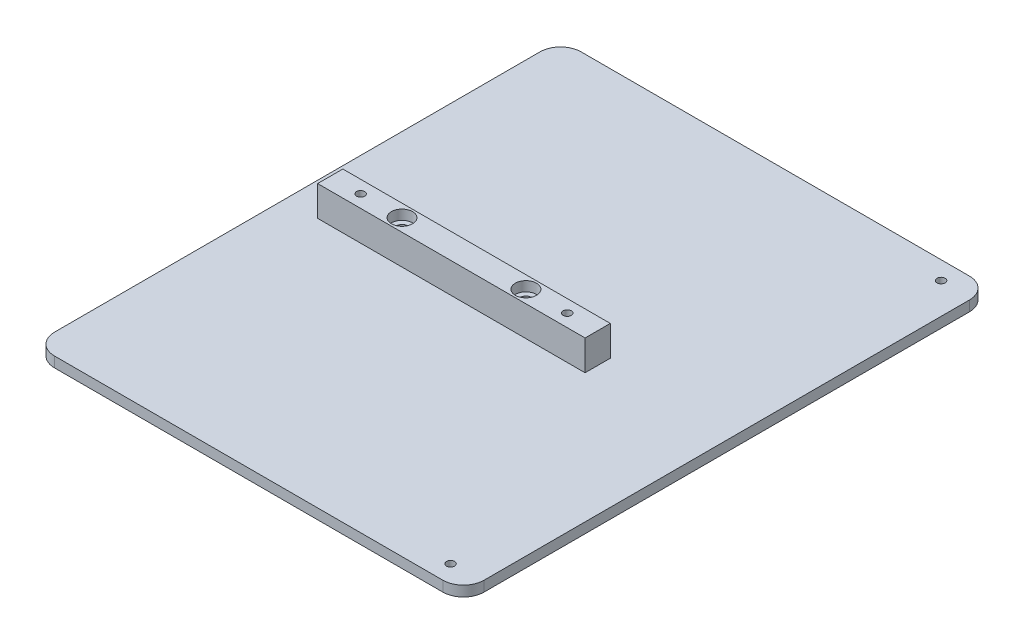
from build123d import *

# Parameters (mm, degrees)
SKETCH1_W                      = 132.08
SKETCH1_H                      = 161.925
BOSS_EXTRUDE1_DEPTH            = 3.175
FILLET1_R                      = 6.35
TAP_DRILL_FOR_M3X0_5_TAP1_D    = 2.5
SKETCH5_W                      = 82.226471496
SKETCH5_H                      = 7.747
BOSS_EXTRUDE2_DEPTH            = 9.271
TAP_DRILL_FOR_M3X0_5_TAP2_D    = 2.5
CBORE_FOR_M3_SHCS1_D           = 3.4
CBORE_FOR_M3_SHCS1_CBORE_D     = 6.5
CBORE_FOR_M3_SHCS1_CBORE_DEPTH = 3


with BuildPart() as part:
    # Sketch1 → Boss-Extrude1 (new body)
    with BuildSketch(Plane(origin=(0, 0, 0), x_dir=(1, 0, 0), z_dir=(0, 1, 0))):
        Rectangle(SKETCH1_W, SKETCH1_H)
    extrude(amount=BOSS_EXTRUDE1_DEPTH)

    # Fillet1
    fillet1_edges = [part.edges().sort_by_distance(p)[0] for p in [
        (-66.04, 1.5875, -80.9625),
        (66.04, 1.5875, -80.9625),
        (66.04, 1.5875, 80.9625),
        (-66.04, 1.5875, 80.9625),
    ]]
    fillet(fillet1_edges, radius=FILLET1_R)

    # Tap Drill for M3x0.5 Tap1 (through all)
    with Locations(Plane(origin=(0, 3.175, 0), x_dir=(1, 0, 0), z_dir=(0, 1, 0))):
        with Locations((56.515, -75.40625), (56.515, 75.40625)):
            Hole(TAP_DRILL_FOR_M3X0_5_TAP1_D / 2)

    # Sketch5 → Boss-Extrude2 (add)
    with BuildSketch(Plane(origin=(0, 3.175, 0), x_dir=(1, 0, 0), z_dir=(0, 1, 0))):
        with Locations((-14.7701, 0)):
            Rectangle(SKETCH5_W, SKETCH5_H)
    extrude(amount=BOSS_EXTRUDE2_DEPTH)

    # Tap Drill for M3x0.5 Tap2 (through all)
    with Locations(Plane(origin=(0, 12.446, 0), x_dir=(1, 0, 0), z_dir=(0, 1, 0))):
        with Locations((-46.5201, 0), (16.9799, 0)):
            Hole(TAP_DRILL_FOR_M3X0_5_TAP2_D / 2)

    # CBORE for M3 SHCS1 (through all)
    with Locations(Plane(origin=(0, 12.446, 0), x_dir=(1, 0, 0), z_dir=(0, 1, 0))):
        with Locations((4.2799, 0), (-33.8201, 0)):
            CounterBoreHole(CBORE_FOR_M3_SHCS1_D / 2, CBORE_FOR_M3_SHCS1_CBORE_D / 2, CBORE_FOR_M3_SHCS1_CBORE_DEPTH)


solid = part.part
